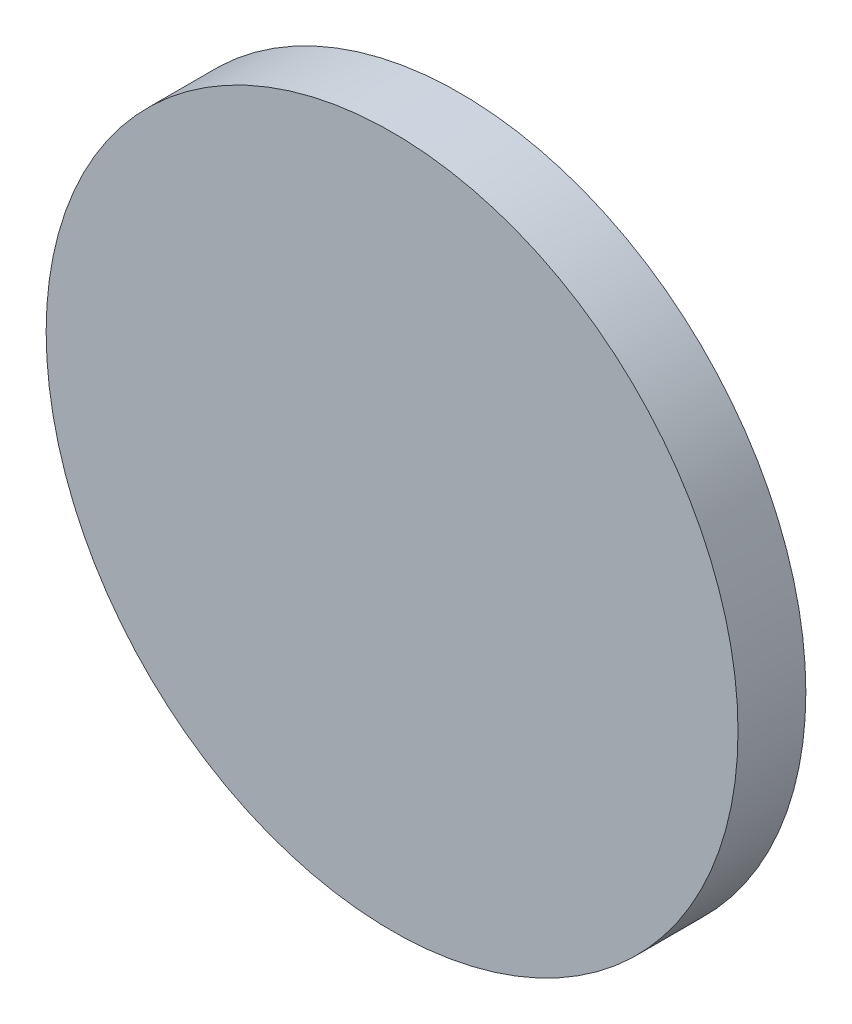
from build123d import *

# Parameters (mm, degrees)
SKETCH1_R           = 12.75
BOSS_EXTRUDE1_DEPTH = 2.5


with BuildPart() as part:
    # Sketch1 → Boss-Extrude1 (new body)
    with BuildSketch(Plane.XY):
        Circle(SKETCH1_R)
    extrude(amount=BOSS_EXTRUDE1_DEPTH)


solid = part.part
